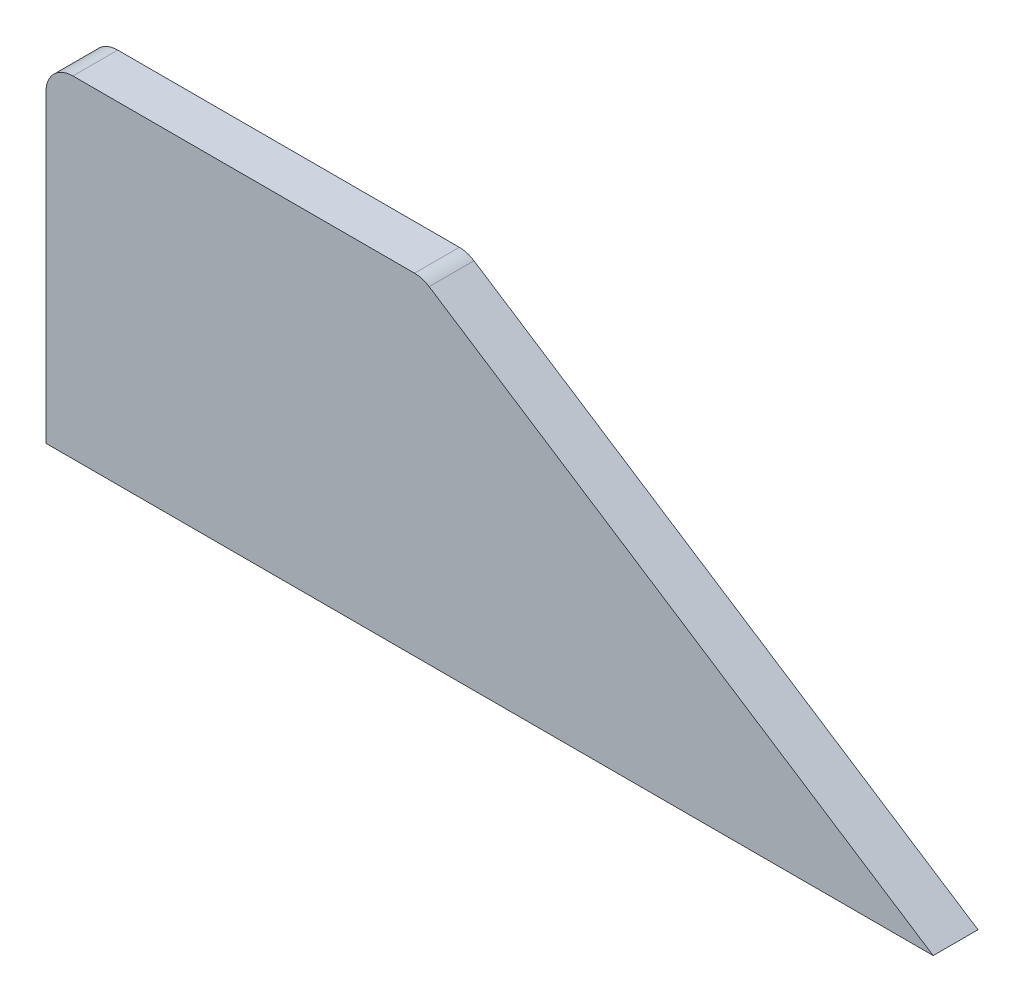
from build123d import *

# Parameters (mm, degrees)
SALIENTE_EXTRUIR1_DEPTH = 5


with BuildPart() as part:
    # Croquis1 → Saliente-Extruir1 (new body)
    with BuildSketch(Plane.XY):
        with BuildLine():
            Line((0, 0), (98.975003661, 0))
            Line((98.975003661, 0), (42.74527662, 36.516011704))
            ThreePointArc((42.74527662, 36.516011704), (41.963405549, 36.876459205), (41.111359515, 37))
            Line((41.111359515, 37), (3, 37))
            ThreePointArc((3, 37), (0.878679656, 36.121320344), (0, 34))
            Line((0, 34), (0, 0))
        make_face()
    extrude(amount=SALIENTE_EXTRUIR1_DEPTH)


solid = part.part
